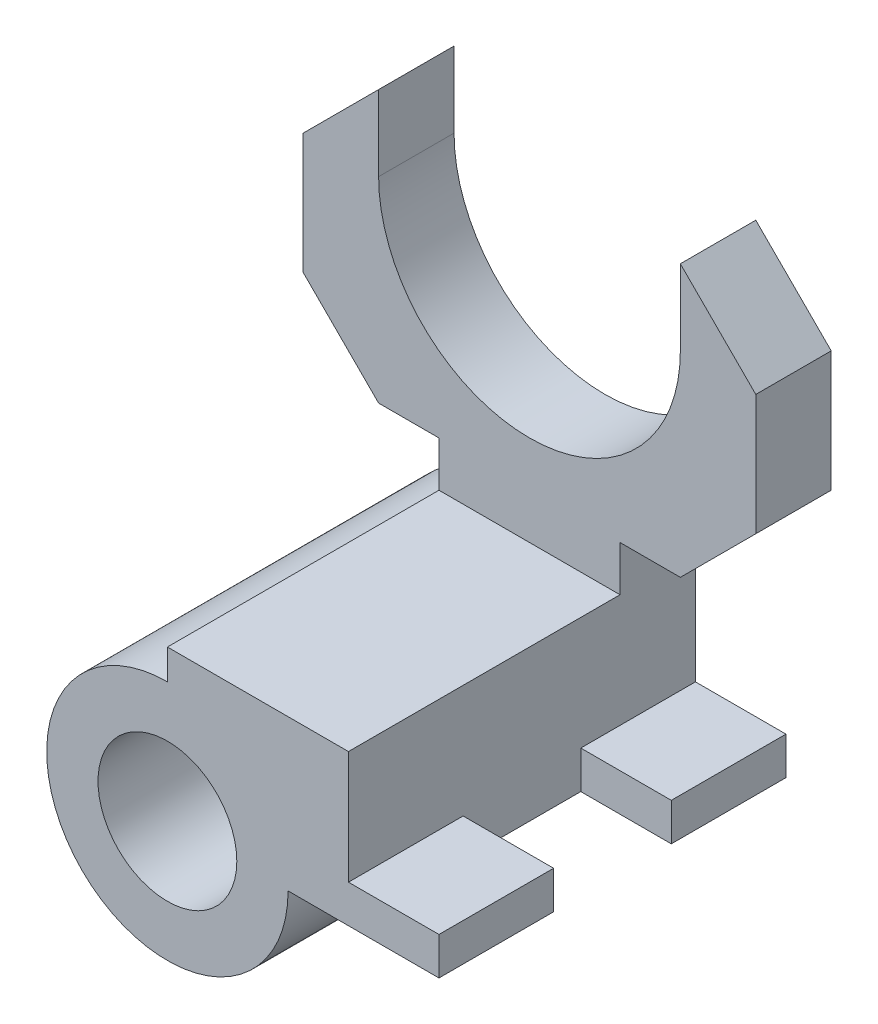
from build123d import *

# Parameters (mm, degrees)
SKETCH1_R           = 11.684
BOSS_EXTRUDE1_DEPTH = 12.7
BOSS_EXTRUDE2_START = 12.7
SKETCH1_3_R         = 11.684
BOSS_EXTRUDE2_DEPTH = 45.72
SKETCH1_4_W         = 15.24
SKETCH1_4_H         = 6.35
BOSS_EXTRUDE3_DEPTH = 19.304
BOSS_EXTRUDE5_START = 39.116
SKETCH1_5_W         = 15.24
SKETCH1_5_H         = 6.35
BOSS_EXTRUDE5_DEPTH = 19.304


with BuildPart() as part:
    # Sketch1 → Boss-Extrude1 (new body)
    with BuildSketch(Plane.XY):
        with BuildLine():
            Line((-10.16, 0), (0, 0))
            Line((0, 0), (0, 6.35))
            Line((0, 6.35), (0, 25.4))
            Line((0, 25.4), (-30.48, 25.4))
            Line((-30.48, 25.4), (-30.48, 20.32))
            ThreePointArc((-30.48, 20.32), (-44.848409794, -14.368409794), (-10.16, 0))
        make_face()
        with Locations((-30.48, 0)):
            Circle(SKETCH1_R, mode=Mode.SUBTRACT)
        with BuildLine():
            Line((-30.48, 25.4), (0, 25.4))
            Line((0, 25.4), (0, 33.02))
            Line((0, 33.02), (10.16, 33.02))
            Line((10.16, 33.02), (22.86, 45.72))
            Line((22.86, 45.72), (22.86, 66.04))
            Line((22.86, 66.04), (10.16, 78.74))
            Line((10.16, 78.74), (10.16, 66.04))
            ThreePointArc((10.16, 66.04), (-15.24, 40.64), (-40.64, 66.04))
            Line((-40.64, 66.04), (-40.64, 78.74))
            Line((-40.64, 78.74), (-53.34, 66.04))
            Line((-53.34, 66.04), (-53.34, 45.72))
            Line((-53.34, 45.72), (-40.64, 33.02))
            Line((-40.64, 33.02), (-30.48, 33.02))
            Line((-30.48, 33.02), (-30.48, 25.4))
        make_face()
    extrude(amount=BOSS_EXTRUDE1_DEPTH)

    # Sketch1_3 → Boss-Extrude2 (add)
    with BuildSketch(Plane.XY.offset(BOSS_EXTRUDE2_START)):
        with BuildLine():
            Line((-30.48, 20.32), (-30.48, 25.4))
            Line((-30.48, 25.4), (0, 25.4))
            Line((0, 25.4), (0, 0))
            Line((0, 0), (-10.16, 0))
            ThreePointArc((-10.16, 0), (-44.848409794, -14.368409794), (-30.48, 20.32))
        make_face()
        with Locations((-30.48, 0)):
            Circle(SKETCH1_3_R, mode=Mode.SUBTRACT)
    extrude(amount=BOSS_EXTRUDE2_DEPTH)

    # Sketch1_4 → Boss-Extrude3 (add)
    with BuildSketch(Plane.XY):
        with Locations((7.62, 3.175)):
            Rectangle(SKETCH1_4_W, SKETCH1_4_H)
    extrude(amount=BOSS_EXTRUDE3_DEPTH)

    # Sketch1_5 → Boss-Extrude5 (add)
    with BuildSketch(Plane.XY.offset(BOSS_EXTRUDE5_START)):
        with Locations((7.62, 3.175)):
            Rectangle(SKETCH1_5_W, SKETCH1_5_H)
    extrude(amount=BOSS_EXTRUDE5_DEPTH)


solid = part.part
